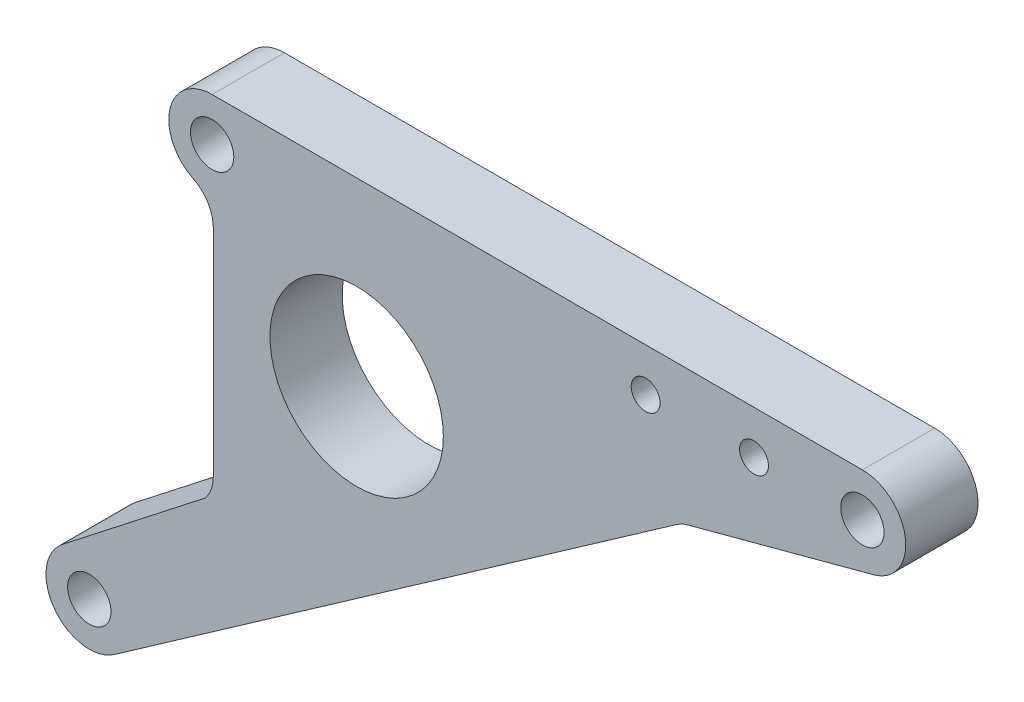
from build123d import *

# Parameters (mm, degrees)
SKETCH2_R           = 3
SKETCH2_R_2         = 2
SKETCH2_R_3         = 12
BOSS_EXTRUDE1_DEPTH = 10


with BuildPart() as part:
    # Sketch2 → Boss-Extrude1 (new body)
    with BuildSketch(Plane.XY):
        with BuildLine():
            Line((16.086311, 54.546287057), (-73.913689, 54.546287057))
            ThreePointArc((-73.913689, 54.546287057), (-79.758605223, 49.901629949), (-76.554310886, 43.158605175))
            ThreePointArc((-76.554310886, 43.158605175), (-74.512035752, 41.314376729), (-73.754829124, 38.668870274))
            Line((-73.754829124, 38.668870274), (-73.754829124, 8.833412185))
            ThreePointArc((-73.754829124, 8.833412185), (-74.03645611, 7.179037348), (-74.849611564, 5.711029151))
            Line((-74.849611564, 5.711029151), (-94.607657852, -9.725648422))
            ThreePointArc((-94.607657852, -9.725648422), (-95.736830164, -18.022649664), (-87.472230382, -19.368625209))
            Line((-87.472230382, -19.368625209), (-9.642261307, 35.128505836))
            ThreePointArc((-9.642261307, 35.128505836), (-8.887470434, 35.56428455), (-8.06847435, 35.862374746))
            Line((-8.06847435, 35.862374746), (17.63922527, 42.750732099))
            ThreePointArc((17.63922527, 42.750732099), (22.034980168, 49.32944421), (16.086311, 54.546287057))
        make_face()
        with Locations((16.086311, 48.546287057)):
            Circle(SKETCH2_R, mode=Mode.SUBTRACT)
        with Locations((1.086311, 48.546287057)):
            Circle(SKETCH2_R_2, mode=Mode.SUBTRACT)
        with Locations((-13.913689, 48.546287057)):
            Circle(SKETCH2_R_2, mode=Mode.SUBTRACT)
        with Locations((-73.913689, 48.546287057)):
            Circle(SKETCH2_R, mode=Mode.SUBTRACT)
        with Locations((-90.913689, -14.453712943)):
            Circle(SKETCH2_R, mode=Mode.SUBTRACT)
        with Locations((-53.913689, 29.546287057)):
            Circle(SKETCH2_R_3, mode=Mode.SUBTRACT)
    extrude(amount=BOSS_EXTRUDE1_DEPTH)


solid = part.part
